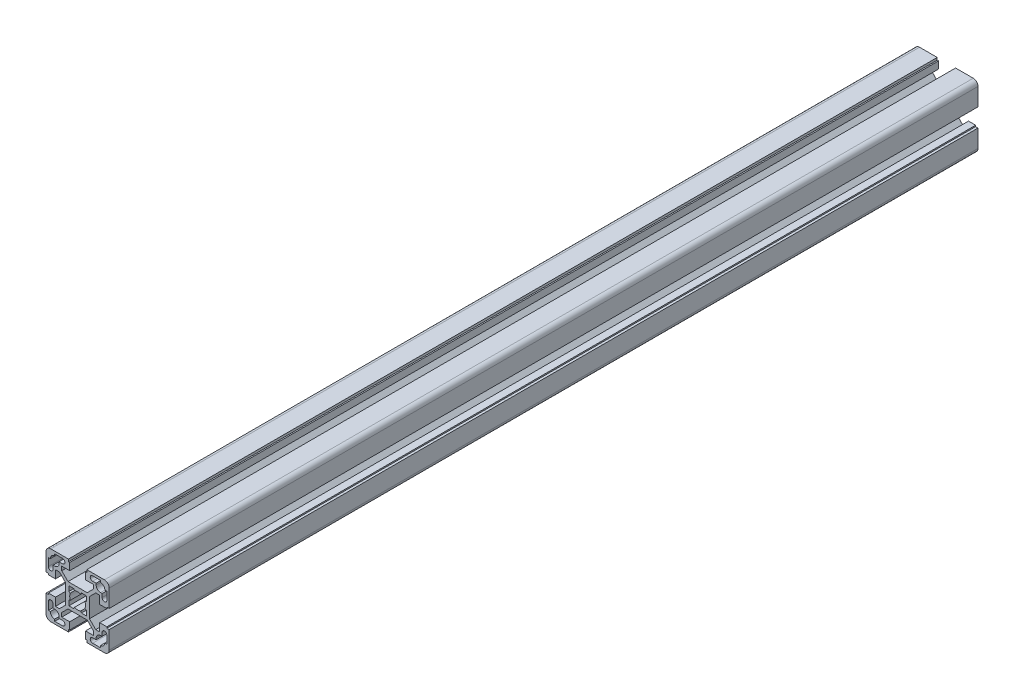
from build123d import *

# Parameters (mm, degrees)
EXTRUDE1_DEPTH = 275


with BuildPart() as part:
    # Sketch1 → Extrude1 (new body, symmetric)
    with BuildSketch(Plane.XY):
        with BuildLine():
            Line((5.8, -20), (17, -20))
            ThreePointArc((17, -20), (19.121320344, -19.121320344), (20, -17))
            Line((20, -17), (20, -5.8))
            Line((20, -5.8), (18.5, -5.8))
            Line((18.5, -5.8), (18.5, -5))
            Line((18.5, -5), (14, -5))
            Line((14, -5), (14, -10.05))
            Line((14, -10.05), (11.464213562, -10.05))
            Line((11.464213562, -10.05), (7.5, -6.085786438))
            Line((7.5, -6.085786438), (7.5, 6.085786438))
            Line((7.5, 6.085786438), (11.464213562, 10.05))
            Line((11.464213562, 10.05), (14, 10.05))
            Line((14, 10.05), (14, 5))
            Line((14, 5), (18.5, 5))
            Line((18.5, 5), (18.5, 5.8))
            Line((18.5, 5.8), (20, 5.8))
            Line((20, 5.8), (20, 17))
            ThreePointArc((20, 17), (19.121320344, 19.121320344), (17, 20))
            Line((17, 20), (5.8, 20))
            Line((5.8, 20), (5.8, 18.5))
            Line((5.8, 18.5), (5, 18.5))
            Line((5, 18.5), (5, 14))
            Line((5, 14), (10.05, 14))
            Line((10.05, 14), (10.05, 11.464213562))
            Line((10.05, 11.464213562), (6.085786438, 7.5))
            Line((6.085786438, 7.5), (-6.085786438, 7.5))
            Line((-6.085786438, 7.5), (-10.05, 11.464213562))
            Line((-10.05, 11.464213562), (-10.05, 14))
            Line((-10.05, 14), (-5, 14))
            Line((-5, 14), (-5, 18.5))
            Line((-5, 18.5), (-5.8, 18.5))
            Line((-5.8, 18.5), (-5.8, 20))
            Line((-5.8, 20), (-17, 20))
            ThreePointArc((-17, 20), (-19.121320344, 19.121320344), (-20, 17))
            Line((-20, 17), (-20, 5.8))
            Line((-20, 5.8), (-18.5, 5.8))
            Line((-18.5, 5.8), (-18.5, 5))
            Line((-18.5, 5), (-14, 5))
            Line((-14, 5), (-14, 10.05))
            Line((-14, 10.05), (-11.464213562, 10.05))
            Line((-11.464213562, 10.05), (-7.5, 6.085786438))
            Line((-7.5, 6.085786438), (-7.5, -6.085786438))
            Line((-7.5, -6.085786438), (-11.464213562, -10.05))
            Line((-11.464213562, -10.05), (-14, -10.05))
            Line((-14, -10.05), (-14, -5))
            Line((-14, -5), (-18.5, -5))
            Line((-18.5, -5), (-18.5, -5.8))
            Line((-18.5, -5.8), (-20, -5.8))
            Line((-20, -5.8), (-20, -17))
            ThreePointArc((-20, -17), (-19.121320344, -19.121320344), (-17, -20))
            Line((-17, -20), (-5.8, -20))
            Line((-5.8, -20), (-5.8, -18.5))
            Line((-5.8, -18.5), (-5, -18.5))
            Line((-5, -18.5), (-5, -14))
            Line((-5, -14), (-10.05, -14))
            Line((-10.05, -14), (-10.05, -11.464213562))
            Line((-10.05, -11.464213562), (-6.085786438, -7.5))
            Line((-6.085786438, -7.5), (6.085786438, -7.5))
            Line((6.085786438, -7.5), (10.05, -11.464213562))
            Line((10.05, -11.464213562), (10.05, -14))
            Line((10.05, -14), (5, -14))
            Line((5, -14), (5, -18.5))
            Line((5, -18.5), (5.8, -18.5))
            Line((5.8, -18.5), (5.8, -20))
        make_face()
        with BuildLine():
            Line((14.5, -18.5), (9.5, -18.5))
            ThreePointArc((9.5, -18.5), (8, -17), (9.5, -15.5))
            Line((9.5, -15.5), (11.75, -15.5))
            Line((11.75, -15.5), (11.75, -14.5))
            ThreePointArc((11.75, -14.5), (12.555456352, -12.555456352), (14.5, -11.75))
            Line((14.5, -11.75), (15.5, -11.75))
            Line((15.5, -11.75), (15.5, -9.5))
            ThreePointArc((15.5, -9.5), (17, -8), (18.5, -9.5))
            Line((18.5, -9.5), (18.5, -14.5))
            Line((18.5, -14.5), (17.25, -14.5))
            ThreePointArc((17.25, -14.5), (16.444543648, -16.444543648), (14.5, -17.25))
            Line((14.5, -17.25), (14.5, -18.5))
        make_face(mode=Mode.SUBTRACT)
        with BuildLine():
            Line((18.5, 14.5), (17.25, 14.5))
            ThreePointArc((17.25, 14.5), (16.444543648, 16.444543648), (14.5, 17.25))
            Line((14.5, 17.25), (14.5, 18.5))
            Line((14.5, 18.5), (9.5, 18.5))
            ThreePointArc((9.5, 18.5), (8, 17), (9.5, 15.5))
            Line((9.5, 15.5), (11.75, 15.5))
            Line((11.75, 15.5), (11.75, 14.5))
            ThreePointArc((11.75, 14.5), (12.555456352, 12.555456352), (14.5, 11.75))
            Line((14.5, 11.75), (15.5, 11.75))
            Line((15.5, 11.75), (15.5, 9.5))
            ThreePointArc((15.5, 9.5), (17, 8), (18.5, 9.5))
            Line((18.5, 9.5), (18.5, 14.5))
        make_face(mode=Mode.SUBTRACT)
        with BuildLine():
            Line((5.5, 5.5), (2.397915762, 5.5))
            Line((2.397915762, 5.5), (1.998263135, 4.583333333))
            ThreePointArc((1.998263135, 4.583333333), (0, 5), (-1.998263135, 4.583333333))
            Line((-1.998263135, 4.583333333), (-2.397915762, 5.5))
            Line((-2.397915762, 5.5), (-5.5, 5.5))
            Line((-5.5, 5.5), (-5.5, 2.397915762))
            Line((-5.5, 2.397915762), (-4.583333333, 1.998263135))
            ThreePointArc((-4.583333333, 1.998263135), (-5, 0), (-4.583333333, -1.998263135))
            Line((-4.583333333, -1.998263135), (-5.5, -2.397915762))
            Line((-5.5, -2.397915762), (-5.5, -5.5))
            Line((-5.5, -5.5), (-2.397915762, -5.5))
            Line((-2.397915762, -5.5), (-1.998263135, -4.583333333))
            ThreePointArc((-1.998263135, -4.583333333), (0, -5), (1.998263135, -4.583333333))
            Line((1.998263135, -4.583333333), (2.397915762, -5.5))
            Line((2.397915762, -5.5), (5.5, -5.5))
            Line((5.5, -5.5), (5.5, -2.397915762))
            Line((5.5, -2.397915762), (4.583333333, -1.998263135))
            ThreePointArc((4.583333333, -1.998263135), (5, 0), (4.583333333, 1.998263135))
            Line((4.583333333, 1.998263135), (5.5, 2.397915762))
            Line((5.5, 2.397915762), (5.5, 5.5))
        make_face(mode=Mode.SUBTRACT)
        with BuildLine():
            Line((-18.5, -14.5), (-17.25, -14.5))
            ThreePointArc((-17.25, -14.5), (-16.444543648, -16.444543648), (-14.5, -17.25))
            Line((-14.5, -17.25), (-14.5, -18.5))
            Line((-14.5, -18.5), (-9.5, -18.5))
            ThreePointArc((-9.5, -18.5), (-8, -17), (-9.5, -15.5))
            Line((-9.5, -15.5), (-11.75, -15.5))
            Line((-11.75, -15.5), (-11.75, -14.5))
            ThreePointArc((-11.75, -14.5), (-12.555456352, -12.555456352), (-14.5, -11.75))
            Line((-14.5, -11.75), (-15.5, -11.75))
            Line((-15.5, -11.75), (-15.5, -9.5))
            ThreePointArc((-15.5, -9.5), (-17, -8), (-18.5, -9.5))
            Line((-18.5, -9.5), (-18.5, -14.5))
        make_face(mode=Mode.SUBTRACT)
        with BuildLine():
            Line((-14.5, 18.5), (-9.5, 18.5))
            ThreePointArc((-9.5, 18.5), (-8, 17), (-9.5, 15.5))
            Line((-9.5, 15.5), (-11.75, 15.5))
            Line((-11.75, 15.5), (-11.75, 14.5))
            ThreePointArc((-11.75, 14.5), (-12.555456352, 12.555456352), (-14.5, 11.75))
            Line((-14.5, 11.75), (-15.5, 11.75))
            Line((-15.5, 11.75), (-15.5, 9.5))
            ThreePointArc((-15.5, 9.5), (-17, 8), (-18.5, 9.5))
            Line((-18.5, 9.5), (-18.5, 14.5))
            Line((-18.5, 14.5), (-17.25, 14.5))
            ThreePointArc((-17.25, 14.5), (-16.444543648, 16.444543648), (-14.5, 17.25))
            Line((-14.5, 17.25), (-14.5, 18.5))
        make_face(mode=Mode.SUBTRACT)
    extrude(amount=EXTRUDE1_DEPTH, both=True)


solid = part.part
